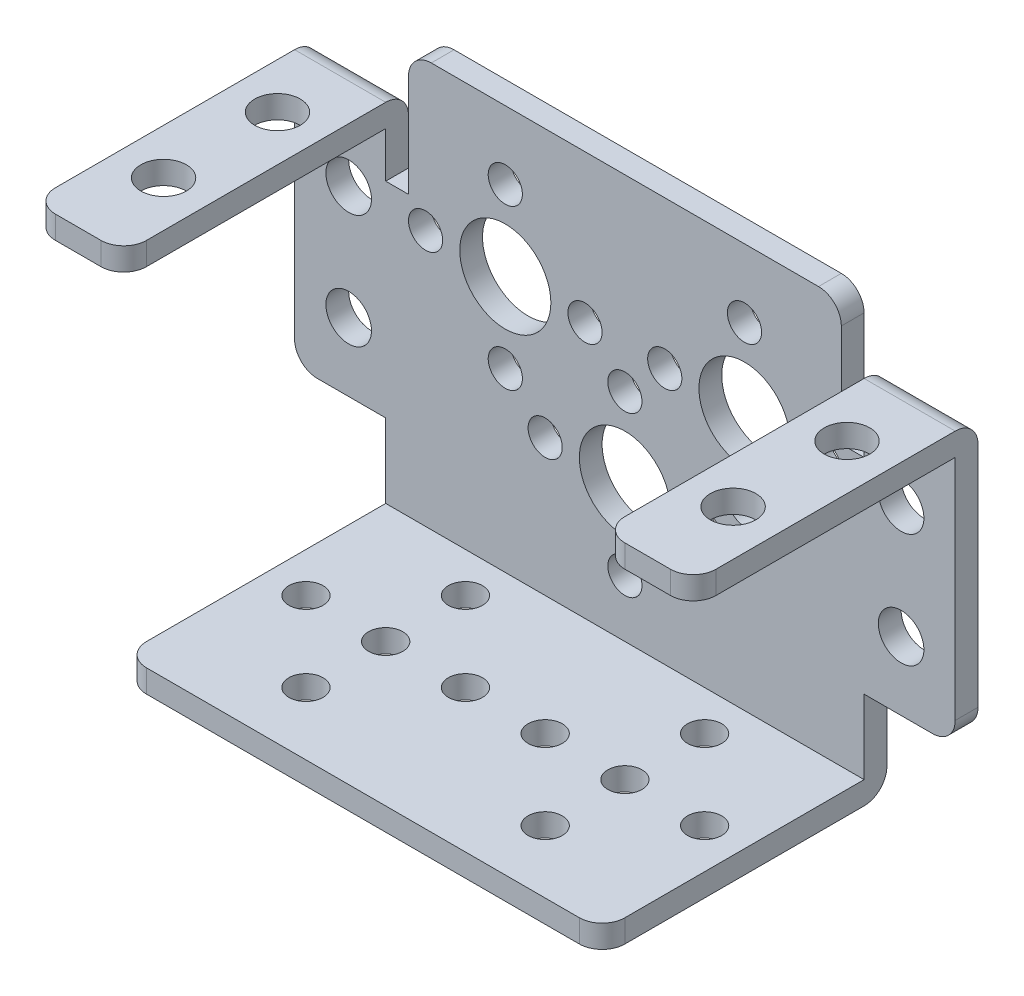
from build123d import *

# Parameters (mm, degrees)
CROQUIS1_R                 = 1.5
CROQUIS1_R_2               = 2
CROQUIS1_R_3               = 4
SALIENTE_EXTRUIR1_DEPTH    = 2
CROQUIS2_W                 = 42
CROQUIS2_H                 = 2
CROQUIS2_W_2               = 8
SALIENTE_EXTRUIR2_DEPTH    = 25
REDONDEO2_R                = 2
CROQUIS3_R                 = 1.5
CROQUIS3_R_2               = 2
CORTAR_EXTRUIR1_DEPTH      = 25
CORTAR_EXTRUIR1_DEPTH_BACK = 25


with BuildPart() as part:
    # Croquis1 → Saliente-Extruir1 (new body)
    with BuildSketch(Plane.XY):
        with BuildLine():
            Line((-21, -12), (21, -12))
            Line((21, -12), (21, -5.5))
            Line((21, -5.5), (27, -5.5))
            ThreePointArc((27, -5.5), (28.414213562, -4.914213562), (29, -3.5))
            Line((29, -3.5), (29, 16.5))
            Line((29, 16.5), (21, 16.5))
            Line((21, 16.5), (21, 12.5))
            Line((21, 12.5), (19, 12.5))
            Line((19, 12.5), (19, 21.49))
            ThreePointArc((19, 21.49), (18.414213562, 22.904213562), (17, 23.49))
            Line((17, 23.49), (-17, 23.49))
            ThreePointArc((-17, 23.49), (-18.414213562, 22.904213562), (-19, 21.49))
            Line((-19, 21.49), (-19, 12.5))
            Line((-19, 12.5), (-21, 12.5))
            Line((-21, 12.5), (-21, 16.5))
            Line((-21, 16.5), (-29, 16.5))
            Line((-29, 16.5), (-29, -3.5))
            ThreePointArc((-29, -3.5), (-28.414213562, -4.914213562), (-27, -5.5))
            Line((-27, -5.5), (-21, -5.5))
            Line((-21, -5.5), (-21, -12))
        make_face()
        with Locations((0, 7)):
            Circle(CROQUIS1_R, mode=Mode.SUBTRACT)
        with Locations((7, 0)):
            Circle(CROQUIS1_R, mode=Mode.SUBTRACT)
        with Locations((0, -7)):
            Circle(CROQUIS1_R, mode=Mode.SUBTRACT)
        with Locations((-7, 0)):
            Circle(CROQUIS1_R, mode=Mode.SUBTRACT)
        with Locations((-24.25, 10.5)):
            Circle(CROQUIS1_R_2, mode=Mode.SUBTRACT)
        with Locations((24.25, 10.5)):
            Circle(CROQUIS1_R_2, mode=Mode.SUBTRACT)
        with Locations((-24.25, 0.5)):
            Circle(CROQUIS1_R_2, mode=Mode.SUBTRACT)
        Circle(CROQUIS1_R_3, mode=Mode.SUBTRACT)
        with Locations((10.5, 17.5)):
            Circle(CROQUIS1_R, mode=Mode.SUBTRACT)
        with Locations((17.5, 10.5)):
            Circle(CROQUIS1_R, mode=Mode.SUBTRACT)
        with Locations((10.5, 3.5)):
            Circle(CROQUIS1_R, mode=Mode.SUBTRACT)
        with Locations((3.5, 10.5)):
            Circle(CROQUIS1_R, mode=Mode.SUBTRACT)
        with Locations((-10.5, 17.5)):
            Circle(CROQUIS1_R, mode=Mode.SUBTRACT)
        with Locations((-3.5, 10.5)):
            Circle(CROQUIS1_R, mode=Mode.SUBTRACT)
        with Locations((-10.5, 3.5)):
            Circle(CROQUIS1_R, mode=Mode.SUBTRACT)
        with Locations((-17.5, 10.5)):
            Circle(CROQUIS1_R, mode=Mode.SUBTRACT)
        with Locations((-10.5, 10.5)):
            Circle(CROQUIS1_R_3, mode=Mode.SUBTRACT)
        with Locations((10.5, 10.5)):
            Circle(CROQUIS1_R_3, mode=Mode.SUBTRACT)
        with Locations((24.25, 0.5)):
            Circle(CROQUIS1_R_2, mode=Mode.SUBTRACT)
    extrude(amount=SALIENTE_EXTRUIR1_DEPTH)

    # Croquis2 → Saliente-Extruir2 (add)
    with BuildSketch(Plane.XY):
        with Locations((0, -13)):
            Rectangle(CROQUIS2_W, CROQUIS2_H)
        with Locations((-25, 17.5)):
            Rectangle(CROQUIS2_W_2, CROQUIS2_H)
        with Locations((25, 17.5)):
            Rectangle(CROQUIS2_W_2, CROQUIS2_H)
    extrude(amount=SALIENTE_EXTRUIR2_DEPTH)

    # Redondeo2
    redondeo2_edges = [part.edges().sort_by_distance(p)[0] for p in [
        (0, -14, 0),
        (-21, -13, 25),
        (21, -13, 25),
        (-25, 18.5, 0),
        (-21, 17.5, 25),
        (-29, 17.5, 25),
        (25, 18.5, 0),
        (29, 17.5, 25),
        (21, 17.5, 25),
    ]]
    fillet(redondeo2_edges, radius=REDONDEO2_R)

    # Croquis3 → Cortar-Extruir1 (cut, two sides)
    with BuildSketch(Plane(origin=(0, 0, 0), x_dir=(1, 0, 0), z_dir=(0, 1, 0))) as cortar_extruir1_sk:
        with Locations((-10.5, -12.5)):
            Circle(CROQUIS3_R)
        with Locations((10.5, -12.5)):
            Circle(CROQUIS3_R)
        with Locations((-10.5, -5.5)):
            Circle(CROQUIS3_R)
        with Locations((-3.5, -12.5)):
            Circle(CROQUIS3_R)
        with Locations((-10.5, -19.5)):
            Circle(CROQUIS3_R)
        with Locations((-17.5, -12.5)):
            Circle(CROQUIS3_R)
        with Locations((3.5, -12.5)):
            Circle(CROQUIS3_R)
        with Locations((10.5, -19.5)):
            Circle(CROQUIS3_R)
        with Locations((10.5, -5.5)):
            Circle(CROQUIS3_R)
        with Locations((17.5, -12.5)):
            Circle(CROQUIS3_R)
        with Locations((-25, -7.5)):
            Circle(CROQUIS3_R_2)
        with Locations((-25, -17.5)):
            Circle(CROQUIS3_R_2)
        with Locations((25, -17.5)):
            Circle(CROQUIS3_R_2)
        with Locations((25, -7.5)):
            Circle(CROQUIS3_R_2)
    extrude(amount=CORTAR_EXTRUIR1_DEPTH, mode=Mode.SUBTRACT)
    extrude(cortar_extruir1_sk.sketch, amount=-CORTAR_EXTRUIR1_DEPTH_BACK, mode=Mode.SUBTRACT)


solid = part.part
